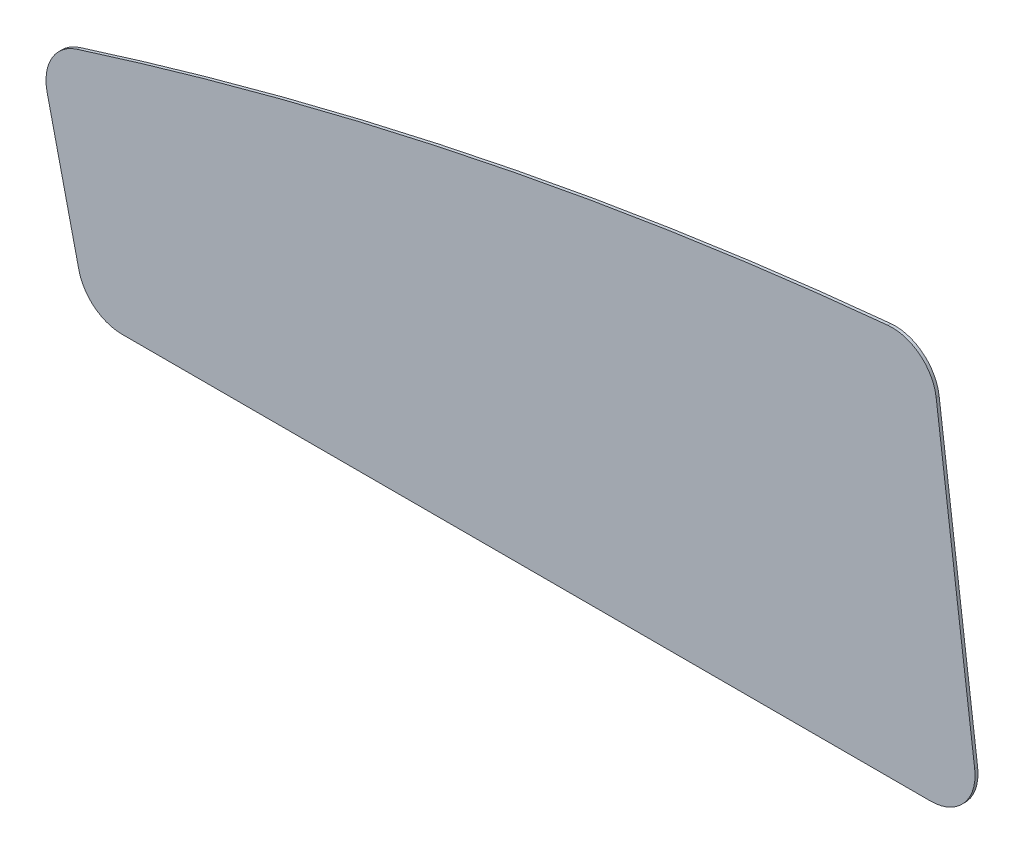
from build123d import *

# Parameters (mm, degrees)
RESSALTO_EXTRUS_O1_DEPTH = 1


with BuildPart() as part:
    # Esboço1 → Ressalto-extrusão1 (new body)
    with BuildSketch(Plane.XY):
        with BuildLine():
            Line((94.444598391, 61.667599804), (367.776904696, 61.667599804))
            ThreePointArc((367.776904696, 61.667599804), (379.03385921, 66.75392364), (382.656611581, 78.563469793))
            Line((382.656611581, 78.563469793), (369.641986092, 180.708560753))
            ThreePointArc((369.641986092, 180.708560753), (364.126605538, 190.530599808), (353.330083137, 193.744161368))
            add(Edge.make_bspline(
                [(79.194488068, 137.503422788), (169.384224686, 166.11838017), (260.762756376, 184.86529303), (353.330083137, 193.744161368)],
                knots=[0.031642667, 0.031642667, 0.031642667, 0.031642667, 0.681355193, 0.681355193, 0.681355193, 0.681355193], degree=3))
            ThreePointArc((79.194488068, 137.503422788), (70.703408387, 130.641376571), (69.113130899, 119.840583547))
            Line((69.113130899, 119.840583547), (79.826960066, 73.302388103))
            ThreePointArc((79.826960066, 73.302388103), (85.103243444, 64.931370096), (94.444598391, 61.667599804))
        make_face()
    extrude(amount=RESSALTO_EXTRUS_O1_DEPTH)


solid = part.part
